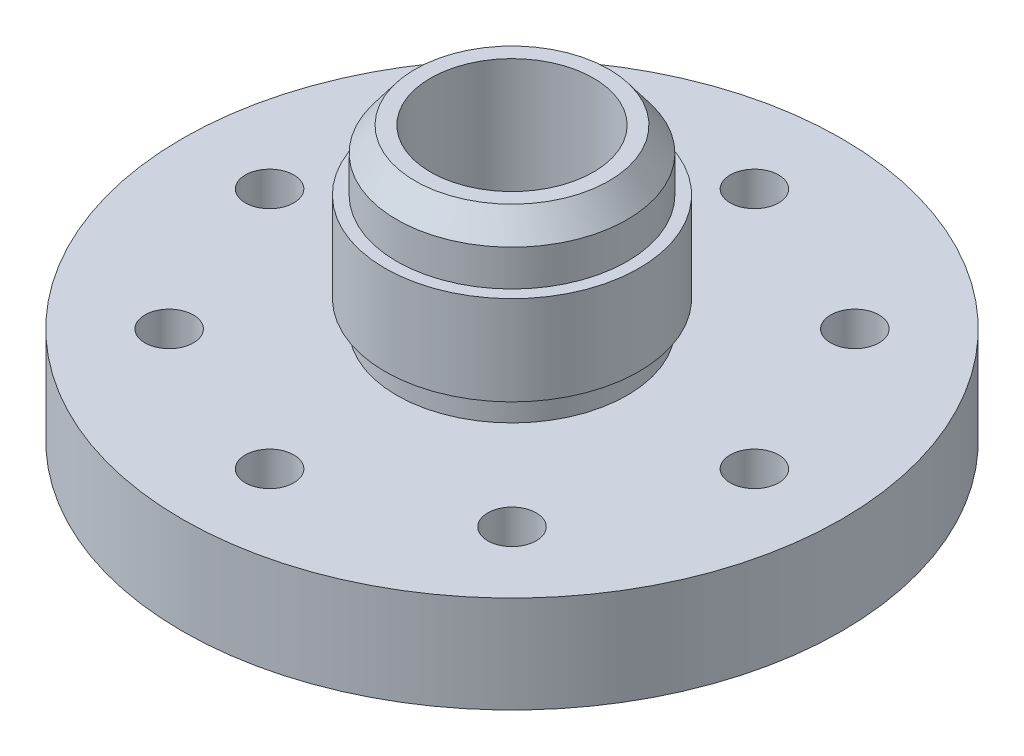
from build123d import *

# Parameters (mm, degrees)
SKETCH1_R              = 43.18
FLANGE_EXTRUDE_DEPTH   = 12.7
SKETCH2_R              = 15.0876
AN_FITTING_BODY_DEPTH  = 23.114
HOLE_FOR_FITTING_REACH = 37.814
SKETCH3_R              = 10.668
SKETCH5_R              = 16.637
SKETCH5_R_2            = 15.0876
MEAT_FOR_THREAD_DEPTH  = 11.7094
SKETCH10_R             = 15.1892
SKETCH10_R_2           = 12.7
O_RING_GROOVE_DEPTH    = 1.26238
SKETCH13_R             = 3.175
BOLT_HOLE_DEPTH        = 12.7
CIRPATTERN1_COUNT      = 8


with BuildPart() as part:
    # Sketch1 → flange extrude (new body)
    with BuildSketch(Plane(origin=(0, 0, 0), x_dir=(1, 0, 0), z_dir=(0, 1, 0))):
        Circle(SKETCH1_R)
    extrude(amount=FLANGE_EXTRUDE_DEPTH)

    # Sketch2 → an fitting body (add)
    with BuildSketch(Plane(origin=(0, 12.7, 0), x_dir=(1, 0, 0), z_dir=(0, 1, 0))):
        Circle(SKETCH2_R)
    extrude(amount=AN_FITTING_BODY_DEPTH)

    # Sketch3 → hole for fitting (cut, up to next)
    with BuildSketch(Plane(origin=(0, 35.814, 0), x_dir=(1, 0, 0), z_dir=(0, 1, 0)), mode=Mode.PRIVATE) as hole_for_fitting_sk1:
        Circle(SKETCH3_R)
    hole_for_fitting_tool1 = extrude(hole_for_fitting_sk1.sketch, amount=-HOLE_FOR_FITTING_REACH, mode=Mode.PRIVATE) & part.part
    add(hole_for_fitting_tool1.solids().sort_by_distance((0, 35.814, 0))[0], mode=Mode.SUBTRACT)

    # Sketch5 → meat for thread (add)
    with BuildSketch(Plane(origin=(0, 16.1798, 0), x_dir=(1, 0, 0), z_dir=(0, 1, 0))):
        Circle(SKETCH5_R)
        Circle(SKETCH5_R_2, mode=Mode.SUBTRACT)
    extrude(amount=MEAT_FOR_THREAD_DEPTH)

    # Sketch6 → Cut-Revolve1 (revolve, cut)
    with BuildSketch(Plane.XY):
        Polygon((12.6873, 35.814), (15.0876, 32.628694315), (15.0876, 35.814), align=None)
    revolve(axis=Axis((0, 0, 0), (0, 1, 0)), mode=Mode.SUBTRACT)

    # Sketch10 → O-ring groove (cut)
    with BuildSketch(Plane.XZ):
        Circle(SKETCH10_R)
        Circle(SKETCH10_R_2, mode=Mode.SUBTRACT)
    extrude(amount=-O_RING_GROOVE_DEPTH, mode=Mode.SUBTRACT)

    # Sketch13 → bolt hole (cut)
    with BuildSketch(Plane.XZ):
        with Locations((0, 31.75)):
            Circle(SKETCH13_R)
    bolt_hole = extrude(amount=-BOLT_HOLE_DEPTH, mode=Mode.SUBTRACT)

    # CirPattern1: bolt hole ×8 about axis
    cirpattern1_axis = Axis((0, 0, 0), (0, 1, 0))
    for i in range(1, CIRPATTERN1_COUNT):
        add(bolt_hole.rotate(cirpattern1_axis, i * 360 / CIRPATTERN1_COUNT), mode=Mode.SUBTRACT)


solid = part.part
